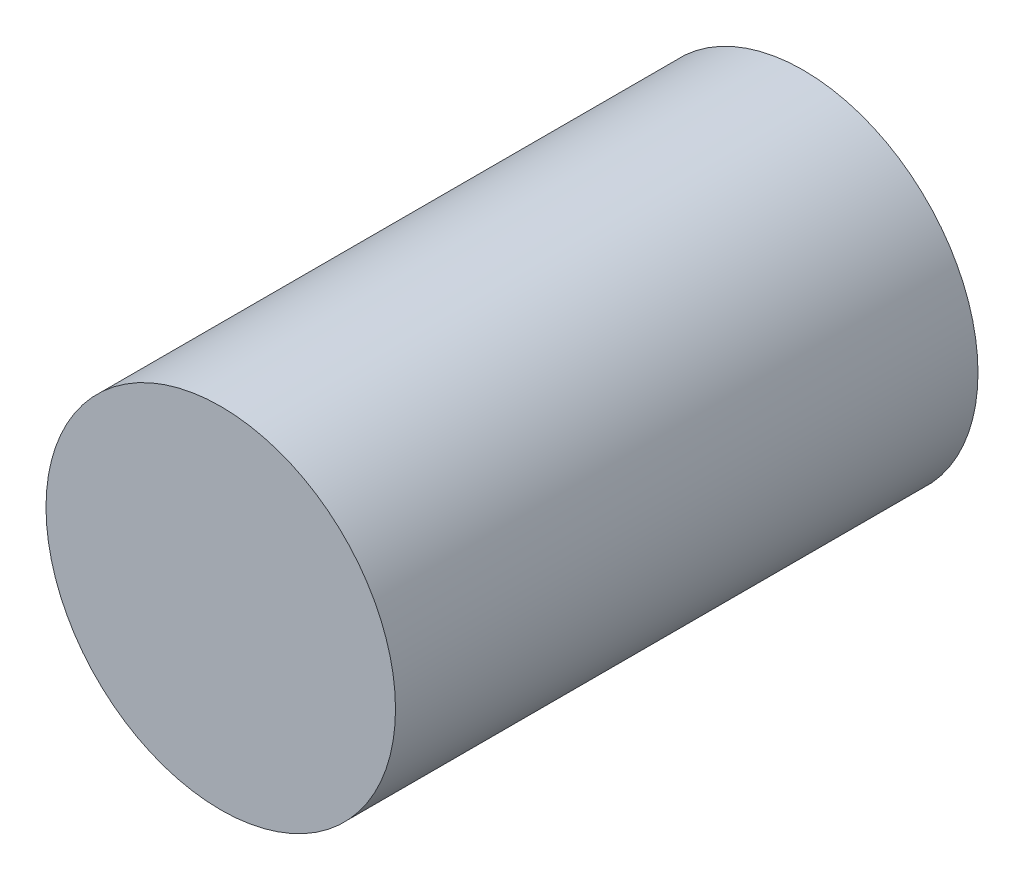
from build123d import *

# Parameters (mm, degrees)
SKETCH2_R           = 6
BOSS_EXTRUDE1_DEPTH = 10


with BuildPart() as part:
    # Sketch2 → Boss-Extrude1 (new body, symmetric)
    with BuildSketch(Plane.XY):
        Circle(SKETCH2_R)
    extrude(amount=BOSS_EXTRUDE1_DEPTH, both=True)


solid = part.part
